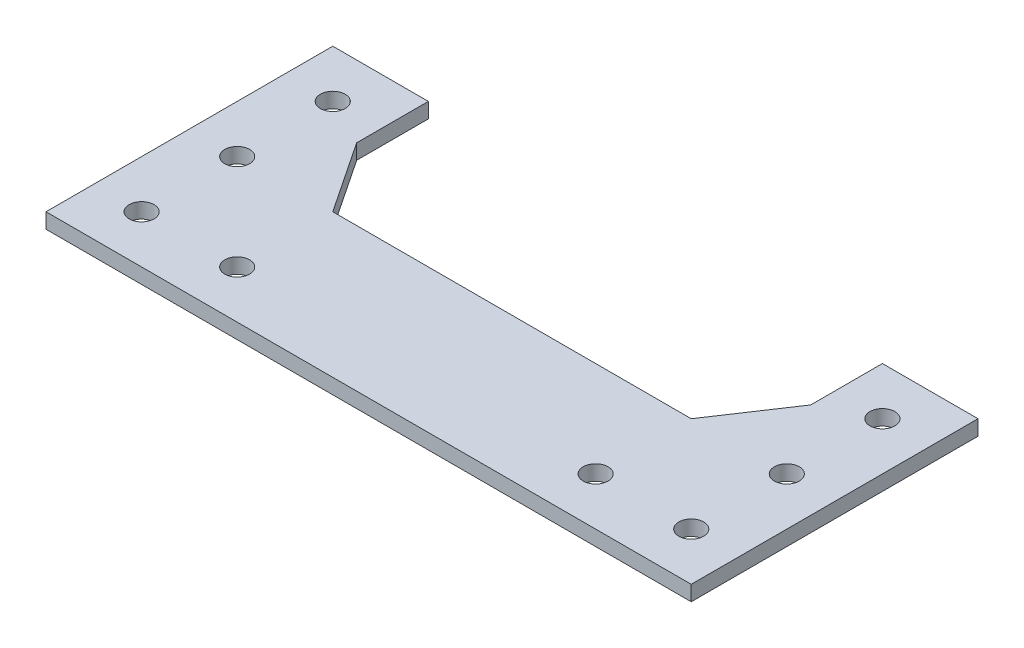
from build123d import *

# Parameters (mm, degrees)
SKETCH1_R           = 2.6
BOSS_EXTRUDE1_DEPTH = 3.175


with BuildPart() as part:
    # Sketch1 → Boss-Extrude1 (new body)
    with BuildSketch(Plane(origin=(0, 0, 0), x_dir=(1, 0, 0), z_dir=(0, 1, 0))):
        Polygon((47.5, 45), (37.5, 30), (-37.5, 30), (-47.5, 45), (-47.5, 60), (-67.5, 60), (-67.5, 0), (67.5, 0), (67.5, 60), (47.5, 60), align=None)
        with Locations((-37.5, 10)):
            Circle(SKETCH1_R, mode=Mode.SUBTRACT)
        with Locations((-57.5, 10)):
            Circle(SKETCH1_R, mode=Mode.SUBTRACT)
        with Locations((-57.5, 30)):
            Circle(SKETCH1_R, mode=Mode.SUBTRACT)
        with Locations((-57.5, 50)):
            Circle(SKETCH1_R, mode=Mode.SUBTRACT)
        with Locations((57.5, 50)):
            Circle(SKETCH1_R, mode=Mode.SUBTRACT)
        with Locations((57.5, 30)):
            Circle(SKETCH1_R, mode=Mode.SUBTRACT)
        with Locations((57.5, 10)):
            Circle(SKETCH1_R, mode=Mode.SUBTRACT)
        with Locations((37.5, 10)):
            Circle(SKETCH1_R, mode=Mode.SUBTRACT)
    extrude(amount=BOSS_EXTRUDE1_DEPTH)


solid = part.part
